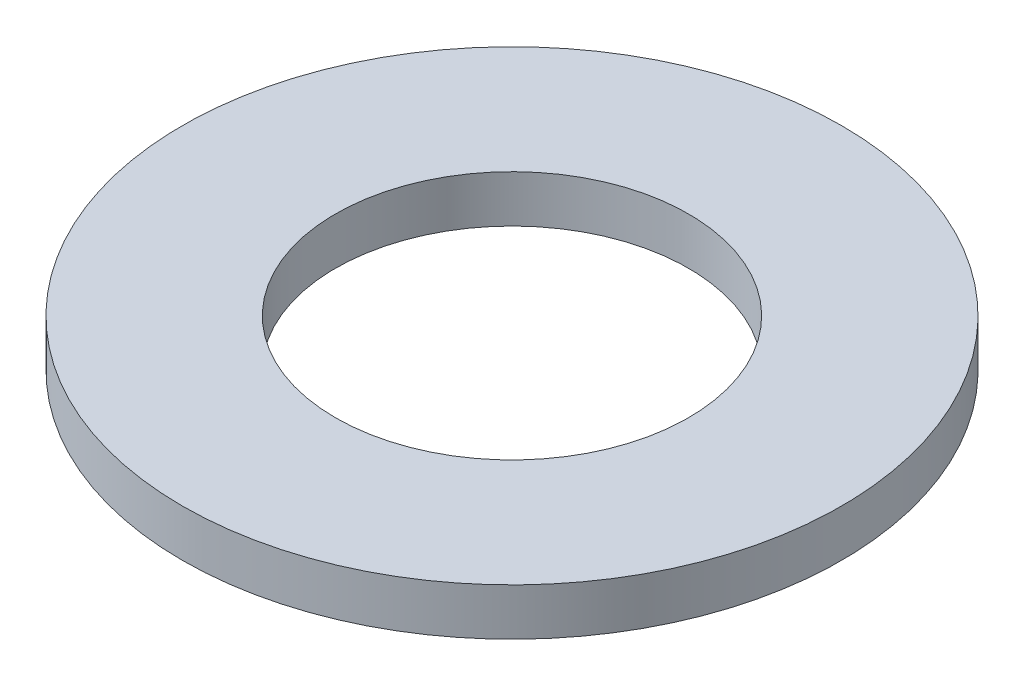
from build123d import *

# Parameters (mm, degrees)
SKETCH1_R           = 14
SKETCH1_R_2         = 7.5
BOSS_EXTRUDE1_DEPTH = 2


with BuildPart() as part:
    # Sketch1 → Boss-Extrude1 (new body)
    with BuildSketch(Plane(origin=(0, 0, 0), x_dir=(1, 0, 0), z_dir=(0, 1, 0))):
        Circle(SKETCH1_R)
        Circle(SKETCH1_R_2, mode=Mode.SUBTRACT)
    extrude(amount=BOSS_EXTRUDE1_DEPTH)


solid = part.part
